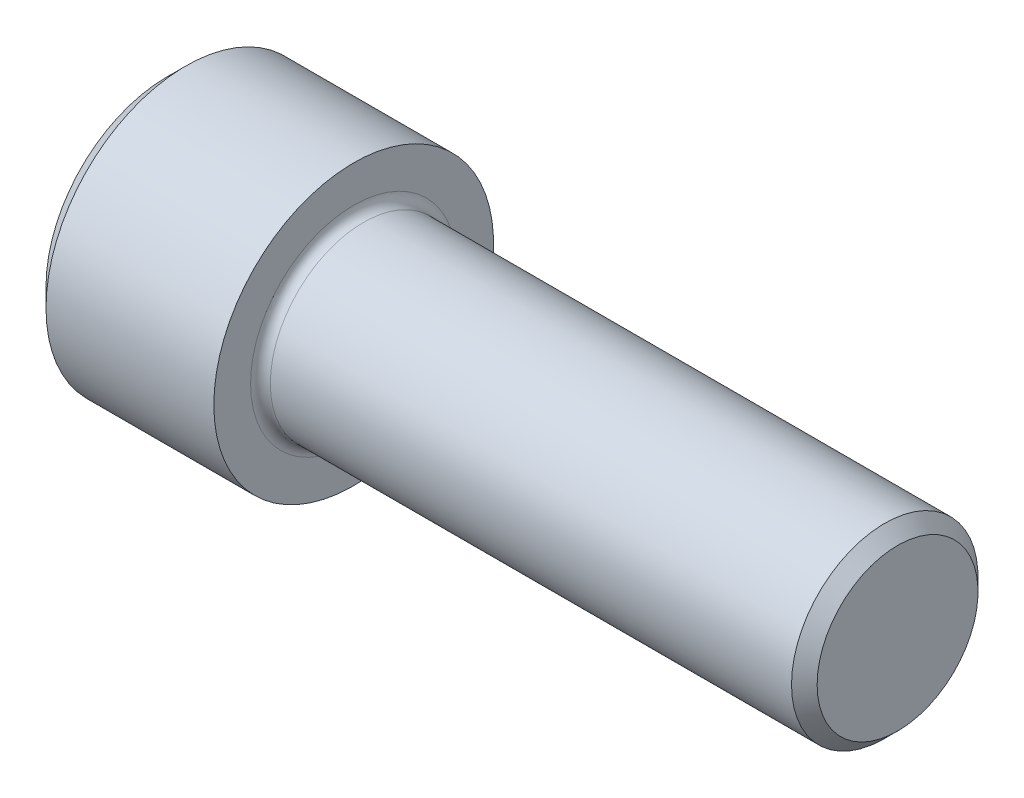
from build123d import *

# Parameters (mm, degrees)
FILLET1_R   = 1.27
HEX_2_DEPTH = 12


with BuildPart() as part:
    # BodySke → Base-Revolve (revolve)
    with BuildSketch(Plane.XY, mode=Mode.PRIVATE) as base_revolve_sk:
        Polygon((0, 0), (0, 15.6), (2.4, 18), (24, 18), (24, 12), (92.352, 12), (94, 10.352), (94, 0), align=None)
    revolve(base_revolve_sk.sketch.rotate(Axis((-31.75, 0, 0), (1, 0, 0)), 90), axis=Axis((-31.75, 0, 0), (1, 0, 0)))  # turned: the seam where the file's is

    # Fillet1
    fillet1_edges = [part.edges().sort_by_distance(p)[0] for p in [
        (24, 0, -12),
    ]]
    fillet(fillet1_edges, radius=FILLET1_R)

    # Sketch2 → Hex-PreBroach (revolve, cut)
    with BuildSketch(Plane.XY, mode=Mode.PRIVATE) as hex_prebroach_sk:
        Polygon((0, 9.5), (12, 9.5), (17.484827557, 0), (0, 0), align=None)
    revolve(hex_prebroach_sk.sketch.rotate(Axis((0, 0, 0), (1, 0, 0)), 90), axis=Axis((0, 0, 0), (1, 0, 0)), mode=Mode.SUBTRACT)  # turned: the seam where the file's is

    # Sketch3 → Hex 2 (cut)
    with BuildSketch(Plane(origin=(0, 0, 0), x_dir=(0, 0.5, 0.866025404), z_dir=(-1, 0, 0))):
        Polygon((5.484827557, 9.5), (-5.484827557, 9.5), (-10.969655115, 0), (-5.484827557, -9.5), (5.484827557, -9.5), (10.969655115, 0), align=None)
    extrude(amount=-HEX_2_DEPTH, mode=Mode.SUBTRACT)


solid = part.part
